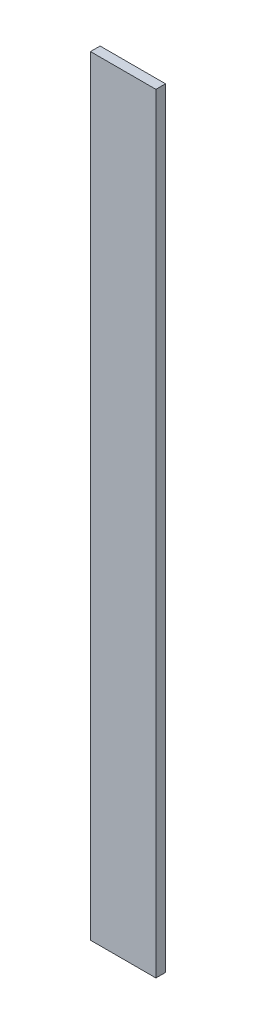
from build123d import *

# Parameters (mm, degrees)
SKETCH1_W           = 43.18
SKETCH1_H           = 6.35
BOSS_EXTRUDE1_DEPTH = 508


with BuildPart() as part:
    # Sketch1 → Boss-Extrude1 (new body)
    with BuildSketch(Plane(origin=(0, 0, 0), x_dir=(1, 0, 0), z_dir=(0, 1, 0))):
        with Locations((21.59, 3.175)):
            Rectangle(SKETCH1_W, SKETCH1_H)
    extrude(amount=BOSS_EXTRUDE1_DEPTH)


solid = part.part
